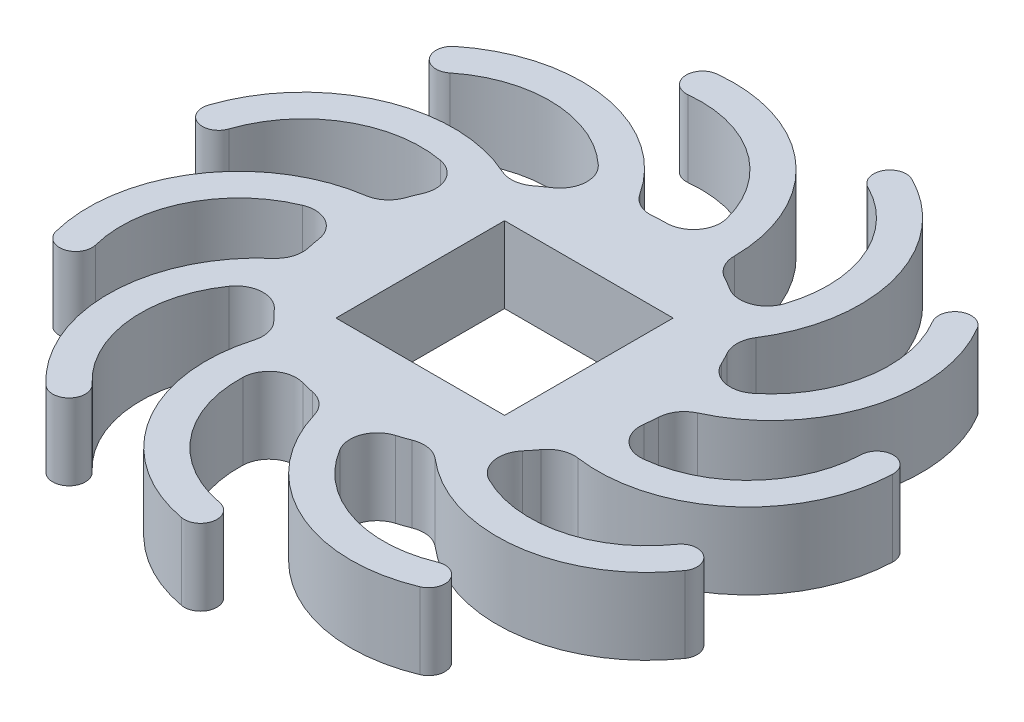
from build123d import *

# Parameters (mm, degrees)
SKETCH1_R           = 6
SKETCH1_W           = 6.2
SKETCH1_H           = 6.2
BOSS_EXTRUDE1_DEPTH = 2.8
BOSS_EXTRUDE5_DEPTH = 2.8
FILLET1_R           = 1


with BuildPart() as part:
    # Sketch1 → Boss-Extrude1 (new body)
    with BuildSketch(Plane(origin=(0, 0, 0), x_dir=(1, 0, 0), z_dir=(0, 1, 0))):
        Circle(SKETCH1_R)
        Rectangle(SKETCH1_W, SKETCH1_H, mode=Mode.SUBTRACT)
    extrude(amount=BOSS_EXTRUDE1_DEPTH)

    # Sketch2 → Boss-Extrude5 (add)
    with BuildSketch(Plane(origin=(0, 0, 0), x_dir=(1, 0, 0), z_dir=(0, 1, 0))):
        with BuildLine():
            ThreePointArc((-0.594853853, -5.732004719), (2.12122611, -9.796172269), (6.998938434, -10.11628274))
            ThreePointArc((6.998938434, -10.11628274), (7.323786775, -9.332399104), (6.539903139, -9.007550763))
            ThreePointArc((6.539903139, -9.007550763), (2.72122611, -8.756941784), (0.594853853, -5.575174958))
            ThreePointArc((0.594853853, -5.575174958), (-0.078414881, -5.058735985), (-0.594853853, -5.732004719))
        make_face()
        with BuildLine():
            ThreePointArc((-2.513744241, -5.011737903), (-2.445119086, -8.838014121), (0.631867012, -11.11337248))
            ThreePointArc((0.631867012, -11.11337248), (1.115685618, -11.810451785), (0.418606313, -12.294270391))
            ThreePointArc((0.418606313, -12.294270391), (-3.511721625, -9.387885947), (-3.599378622, -4.500466947))
            ThreePointArc((-3.599378622, -4.500466947), (-2.800925954, -4.213285234), (-2.513744241, -5.011737903))
        make_face()
        with BuildLine():
            ThreePointArc((-4.8242463, -2.857109475), (-6.835156249, -6.113079421), (-5.476782426, -9.690776959))
            ThreePointArc((-5.476782426, -9.690776959), (-5.44663784, -10.538769473), (-6.294630354, -10.568914059))
            ThreePointArc((-6.294630354, -10.568914059), (-8.029722556, -5.999012169), (-5.461126111, -1.840062718))
            ThreePointArc((-5.461126111, -1.840062718), (-4.634162827, -2.030146191), (-4.8242463, -2.857109475))
        make_face()
        with BuildLine():
            ThreePointArc((-5.603084245, 0.204631024), (-9.055079597, -1.447285198), (-9.846592142, -5.191428224))
            ThreePointArc((-9.846592142, -5.191428224), (-10.279692268, -5.921102316), (-11.00936636, -5.48800219))
            ThreePointArc((-11.00936636, -5.48800219), (-9.998343311, -0.705494414), (-5.589004646, 1.404548423))
            ThreePointArc((-5.589004646, 1.404548423), (-4.996085746, 0.797549924), (-5.603084245, 0.204631024))
        make_face()
        with BuildLine():
            ThreePointArc((-4.602982532, 3.201402618), (-8.400079153, 3.67801185), (-11.090178424, 0.95616229))
            ThreePointArc((-11.090178424, 0.95616229), (-11.849017033, 0.576472989), (-12.228706335, 1.335311598))
            ThreePointArc((-12.228706335, 1.335311598), (-8.792560709, 4.812012832), (-3.942413696, 4.203225364))
            ThreePointArc((-3.942413696, 4.203225364), (-3.771786741, 3.372029573), (-4.602982532, 3.201402618))
        make_face()
        with BuildLine():
            ThreePointArc((-2.141466388, 5.181751502), (-5.078112931, 7.635566123), (-8.812711417, 6.800178034))
            ThreePointArc((-8.812711417, 6.800178034), (-9.656362612, 6.891022193), (-9.565518452, 7.734673388))
            ThreePointArc((-9.565518452, 7.734673388), (-4.795202208, 8.801740005), (-1.044134253, 5.66740795))
            ThreePointArc((-1.044134253, 5.66740795), (-1.349972096, 4.875913658), (-2.141466388, 5.181751502))
        make_face()
        with BuildLine():
            ThreePointArc((0.999950203, 5.516930896), (-0.143881733, 9.168882102), (-3.737270802, 10.485185299))
            ThreePointArc((-3.737270802, 10.485185299), (-4.39788129, 11.017720541), (-3.865346048, 11.678331029))
            ThreePointArc((-3.865346048, 11.678331029), (0.724599113, 9.996976916), (2.185650438, 5.332228556))
            ThreePointArc((2.185650438, 5.332228556), (1.500449151, 4.831729609), (0.999950203, 5.516930896))
        make_face()
        with BuildLine():
            ThreePointArc((3.82388967, 4.100523711), (4.836030899, 7.791142798), (2.524726886, 10.841220317))
            ThreePointArc((2.524726886, 10.841220317), (2.256896268, 11.646370464), (3.062046415, 11.914201083))
            ThreePointArc((3.062046415, 11.914201083), (6.014345335, 8.018244291), (4.721506558, 3.304104271))
            ThreePointArc((4.721506558, 3.304104271), (3.874488394, 3.253505547), (3.82388967, 4.100523711))
        make_face()
        with BuildLine():
            ThreePointArc((5.433771185, 1.382229221), (8.28053789, 3.939770705), (7.985141627, 7.755244484))
            ThreePointArc((7.985141627, 7.755244484), (8.195125207, 8.577380055), (9.017260777, 8.367396474))
            ThreePointArc((9.017260777, 8.367396474), (9.394579409, 3.493775758), (5.758317706, 0.226950226))
            ThreePointArc((5.758317706, 0.226950226), (5.018404948, 0.642316463), (5.433771185, 1.382229221))
        make_face()
        with BuildLine():
            ThreePointArc((5.318468742, -1.77491328), (9.096032608, -1.162450749), (10.910330321, 2.207033324))
            ThreePointArc((10.910330321, 2.207033324), (11.531459797, 2.785132082), (12.109558555, 2.164002607))
            ThreePointArc((12.109558555, 2.164002607), (9.7921009, -2.139941892), (4.966903669, -2.922258912))
            ThreePointArc((4.966903669, -2.922258912), (4.56901339, -2.17280356), (5.318468742, -1.77491328))
        make_face()
        with BuildLine():
            ThreePointArc((3.514590052, -4.368533356), (7.023601243, -5.895602304), (10.371566227, -4.041895323))
            ThreePointArc((10.371566227, -4.041895323), (11.206637378, -3.891375647), (11.357157054, -4.726446798))
            ThreePointArc((11.357157054, -4.726446798), (7.080699542, -7.094243111), (2.598532812, -5.143671494))
            ThreePointArc((2.598532812, -5.143671494), (2.668992363, -4.298073805), (3.514590052, -4.368533356))
        make_face()
    extrude(amount=BOSS_EXTRUDE5_DEPTH)

    # Fillet1
    fillet1_edges = [part.edges().sort_by_distance(p)[0] for p in [
        (-4.149814461, 1.4, -4.333478965),
        (-4.941527662, 1.4, -3.403131552),
        (-1.148190466, 1.4, -5.889113571),
        (-2.317205779, 1.4, -5.534487996),
        (2.217975889, 1.4, -5.574996229),
        (1.042812566, 1.4, -5.908683606),
        (4.879950571, 1.4, -3.490856976),
        (4.07174529, 1.4, -4.406913919),
        (5.992575427, 1.4, -0.298395298),
        (5.807927654, 1.4, -1.505980202),
        (0.66409721, 1.4, 5.963134654),
        (-0.557474339, 1.4, 5.974045728),
        (5.202599926, 1.4, 2.988804779),
        (5.700134025, 1.4, 1.873091589),
        (2.760835709, 1.4, 5.327080456),
        (3.782588118, 1.4, 4.657470036),
        (-3.698790223, 1.4, 4.724293692),
        (-2.66523987, 1.4, 5.375546152),
        (-5.665766346, 1.4, 1.974611788),
        (-5.148382122, 1.4, 3.08125973),
        (-5.833901686, 1.4, -1.401995406),
        (-5.996949428, 1.4, -0.191304886),
    ]]
    fillet(fillet1_edges, radius=FILLET1_R)


solid = part.part
